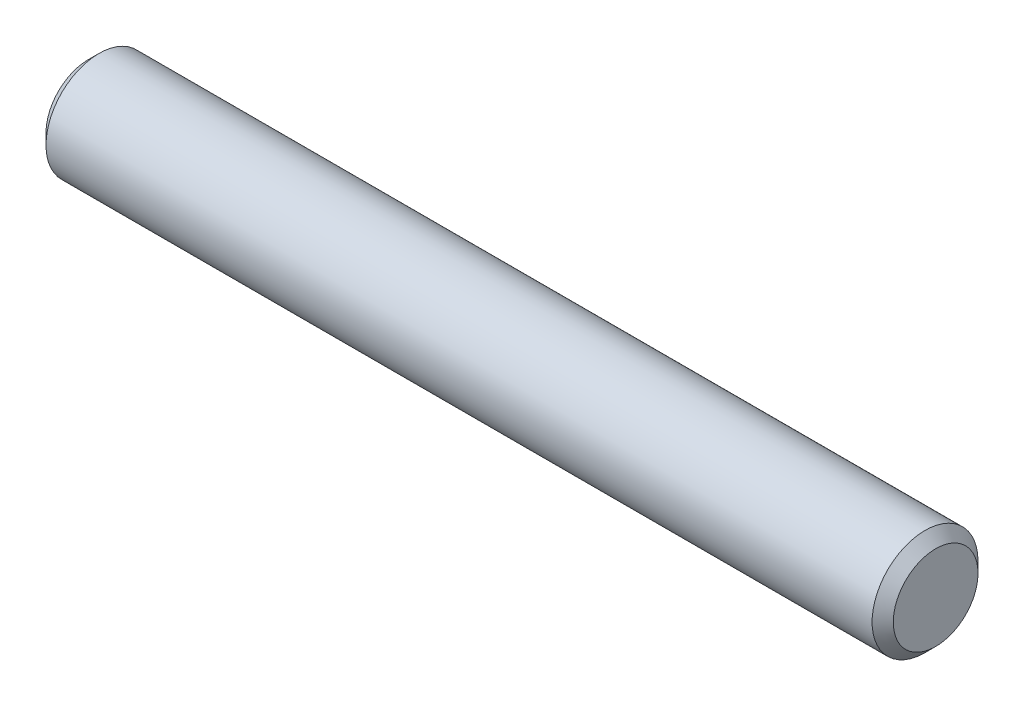
from build123d import *

# Parameters (mm, degrees)
SKETCH2_R           = 3.175
EXTRUDE1_DEPTH      = 25.4
EXTRUDE1_DEPTH_BACK = 25.4
CHAMFER1_SIZE       = 0.635


with BuildPart() as part:
    # Sketch2 → Extrude1 (new body, two sides)
    with BuildSketch(Plane(origin=(0, 0, 0), x_dir=(0, 0, -1), z_dir=(1, 0, 0))) as extrude1_sk:
        Circle(SKETCH2_R)
    extrude(amount=EXTRUDE1_DEPTH)
    extrude(extrude1_sk.sketch, amount=-EXTRUDE1_DEPTH_BACK)

    # Chamfer1
    chamfer1_edges = [part.edges().sort_by_distance(p)[0] for p in [
        (-25.4, 0, 3.175),
        (25.4, 0, 3.175),
    ]]
    chamfer(chamfer1_edges, length=CHAMFER1_SIZE)


solid = part.part
